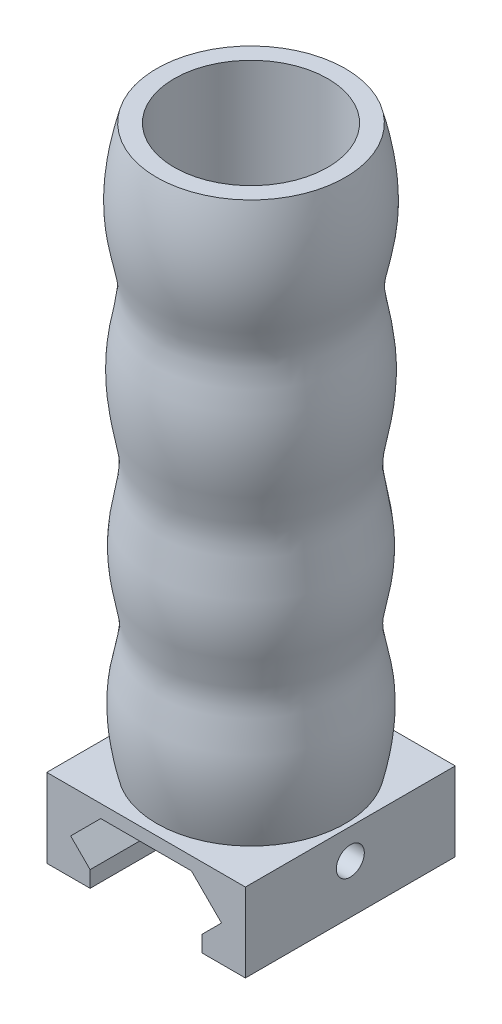
from build123d import *

# Parameters (mm, degrees)
BOSS_EXTRUDE1_DEPTH = 30
SKETCH3_R           = 2
CUT_EXTRUDE2_DEPTH  = 29.4
SKETCH11_R          = 10.983403138
CUT_EXTRUDE3_DEPTH  = 80


with BuildPart() as part:
    # Sketch1 → Boss-Extrude1 (new body)
    with BuildSketch(Plane.XY):
        Polygon((14.2, 13.761910466), (-14.2, 13.761910466), (-14.2, 2.5), (-11.082842712, 2.5), (-8, 2.5), (-8, 4.817157288), (-10.782842712, 7.6), (-6.482842712, 11.9), (6.482842712, 11.9), (10.782842712, 7.6), (8, 4.817157288), (8, 2.5), (11.082842712, 2.5), (14.2, 2.5), align=None)
    extrude(amount=BOSS_EXTRUDE1_DEPTH)

    # Sketch3 → Cut-Extrude2 (cut, through all)
    with BuildSketch(Plane(origin=(14.2, 0, 0), x_dir=(0, 0, -1), z_dir=(1, 0, 0))):
        with Locations(Location((-15, 9.5, 0), (0, 0, 90))):  # turned: the seam where the file's is
            Circle(SKETCH3_R)
    extrude(amount=-CUT_EXTRUDE2_DEPTH, mode=Mode.SUBTRACT)

    # Sketch9 → Revolve2 (revolve)
    with BuildSketch(Plane(origin=(0, 0, 0), x_dir=(0, 0, -1), z_dir=(1, 0, 0))):
        with BuildLine():
            Line((-28.483403138, 93.761910466), (-15, 93.761910466))
            Line((-15, 93.761910466), (-15, 13.761910466))
            Line((-15, 13.761910466), (-28.483403138, 13.761910466))
            add(Edge.make_bspline(
                [(-28.483403138, 13.761910466), (-31.145086737, 24.692296315), (-27.121377906, 28.762236937), (-30.913064787, 43.557319505), (-27.295577593, 49.132991937), (-31.19480755, 65.565333342), (-25.775389052, 74.245854005), (-31.645928371, 82.017446749), (-28.483403138, 93.761910466)],
                knots=[0, 0, 0, 0, 0.086706603, 0.114658805, 0.26120389, 0.315545924, 0.639761013, 1, 1, 1, 1], degree=3))
        make_face()
    revolve(axis=Axis((0, 13.761910466, 15), (0, 1, 0)))

    # Sketch11 → Cut-Extrude3 (cut)
    with BuildSketch(Plane(origin=(0, 93.761910466, 0), x_dir=(1, 0, 0), z_dir=(0, 1, 0))):
        with Locations(Location((0, -15, 0), (0, 0, 270))):  # turned: the seam where the file's is
            Circle(SKETCH11_R)
    extrude(amount=-CUT_EXTRUDE3_DEPTH, mode=Mode.SUBTRACT)


solid = part.part
